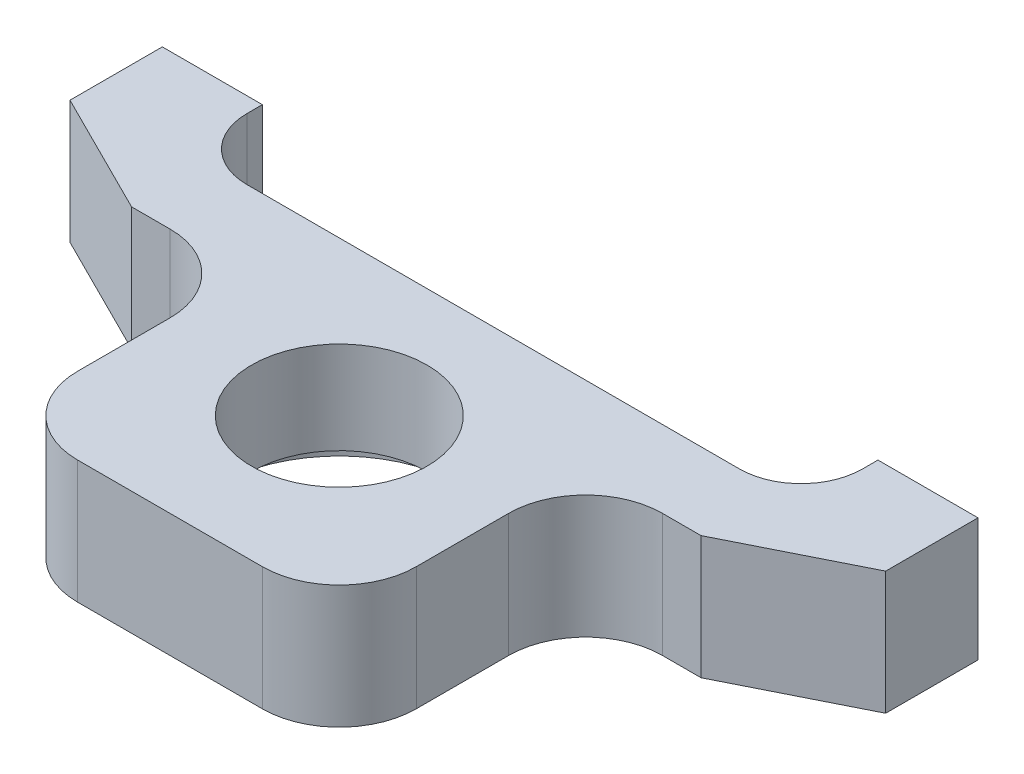
from build123d import *

# Parameters (mm, degrees)
SKETCH1_W                                = 53
SKETCH1_H                                = 26
BOSS_EXTRUDE1_DEPTH                      = 8
SKETCH2_W                                = 15.5
SKETCH2_H                                = 16
CUT_EXTRUDE1_DEPTH                       = 9
SKETCH3_W                                = 15.5
SKETCH3_H                                = 16
CUT_EXTRUDE2_DEPTH                       = 9
SKETCH4_W                                = 40.000000023
SKETCH4_H                                = 5
CUT_EXTRUDE3_DEPTH                       = 9
CBORE_FOR_M10_HEX_HEAD_BOLT1_D           = 11.4
CBORE_FOR_M10_HEX_HEAD_BOLT1_CBORE_D     = 16.2
CBORE_FOR_M10_HEX_HEAD_BOLT1_CBORE_DEPTH = 2
F_3_3_3_3_DIAMETER_HOLE1_D               = 3.3
F_3_3_3_3_DIAMETER_HOLE1_DEPTH           = 6
F_3_3_3_3_DIAMETER_HOLE1_TIP             = 0.991420021
FILLET1_R                                = 4
FILLET2_R                                = 5
CHAMFER1_SIZE                            = 8
CHAMFER1_SIZE2                           = 4
CHAMFER2_SIZE                            = 4
CHAMFER2_SIZE2                           = 8


with BuildPart() as part:
    # Sketch1 → Boss-Extrude1 (new body)
    with BuildSketch(Plane.XZ):
        with Locations((0, 13)):
            Rectangle(SKETCH1_W, SKETCH1_H)
    extrude(amount=-BOSS_EXTRUDE1_DEPTH)

    # Sketch2 → Cut-Extrude1 (cut, through all)
    with BuildSketch(Plane(origin=(0, 8, 0), x_dir=(-1, 0, 0), z_dir=(0, 1, 0))):
        with Locations((-18.75, 18)):
            Rectangle(SKETCH2_W, SKETCH2_H)
    extrude(amount=-CUT_EXTRUDE1_DEPTH, mode=Mode.SUBTRACT)

    # Sketch3 → Cut-Extrude2 (cut, through all)
    with BuildSketch(Plane(origin=(0, 8, 0), x_dir=(-1, 0, 0), z_dir=(0, 1, 0))):
        with Locations((18.75, 18)):
            Rectangle(SKETCH3_W, SKETCH3_H)
    extrude(amount=-CUT_EXTRUDE2_DEPTH, mode=Mode.SUBTRACT)

    # Sketch4 → Cut-Extrude3 (cut, through all)
    with BuildSketch(Plane(origin=(0, 8, 0), x_dir=(-1, 0, 0), z_dir=(0, 1, 0))):
        with Locations((1.2e-08, 2.5)):
            Rectangle(SKETCH4_W, SKETCH4_H)
    extrude(amount=-CUT_EXTRUDE3_DEPTH, mode=Mode.SUBTRACT)

    # CBORE for M10 Hex Head Bolt1 (through all)
    with Locations(Plane(origin=(0, 0, 0), x_dir=(-1, 0, 0), z_dir=(0, -1, 0))):
        with Locations((0, -15)):
            CounterBoreHole(CBORE_FOR_M10_HEX_HEAD_BOLT1_D / 2, CBORE_FOR_M10_HEX_HEAD_BOLT1_CBORE_D / 2, CBORE_FOR_M10_HEX_HEAD_BOLT1_CBORE_DEPTH)

    # Ø3.3 (3.3) Diameter Hole1
    with Locations(Plane(origin=(0, 0, 0), x_dir=(-1, 0, 0), z_dir=(0, 0, -1))):
        with Locations((-23.25, 4), (23.25, 4)):
            Hole(F_3_3_3_3_DIAMETER_HOLE1_D / 2, depth=F_3_3_3_3_DIAMETER_HOLE1_DEPTH)
            with Locations((0, 0, -(F_3_3_3_3_DIAMETER_HOLE1_DEPTH + F_3_3_3_3_DIAMETER_HOLE1_TIP / 2))):  # 118° drill point
                Cone(0, F_3_3_3_3_DIAMETER_HOLE1_D / 2, F_3_3_3_3_DIAMETER_HOLE1_TIP, mode=Mode.SUBTRACT)

    # Fillet1
    fillet1_edges = [part.edges().sort_by_distance(p)[0] for p in [
        (20, 4, 5),
        (-20.000000023, 4, 5),
    ]]
    fillet(fillet1_edges, radius=FILLET1_R)

    # Fillet2
    fillet2_edges = [part.edges().sort_by_distance(p)[0] for p in [
        (11, 4, 10),
        (11, 4, 26),
        (-11, 4, 26),
        (-11, 4, 10),
    ]]
    fillet(fillet2_edges, radius=FILLET2_R)

    # Chamfer1
    chamfer1_edges = [part.edges().sort_by_distance(p)[0] for p in [
        (-26.5, 4, 10),
    ]]
    chamfer1_side = [part.faces().sort_by_distance(p)[0] for p in [
        (-21.25, 4, 10),
    ]]
    chamfer(chamfer1_edges, length=CHAMFER1_SIZE, length2=CHAMFER1_SIZE2, reference=chamfer1_side[0])

    # Chamfer2
    chamfer2_edges = [part.edges().sort_by_distance(p)[0] for p in [
        (26.5, 4, 10),
    ]]
    chamfer2_side = [part.faces().sort_by_distance(p)[0] for p in [
        (26.5, 4, 5),
    ]]
    chamfer(chamfer2_edges, length=CHAMFER2_SIZE, length2=CHAMFER2_SIZE2, reference=chamfer2_side[0])


solid = part.part
